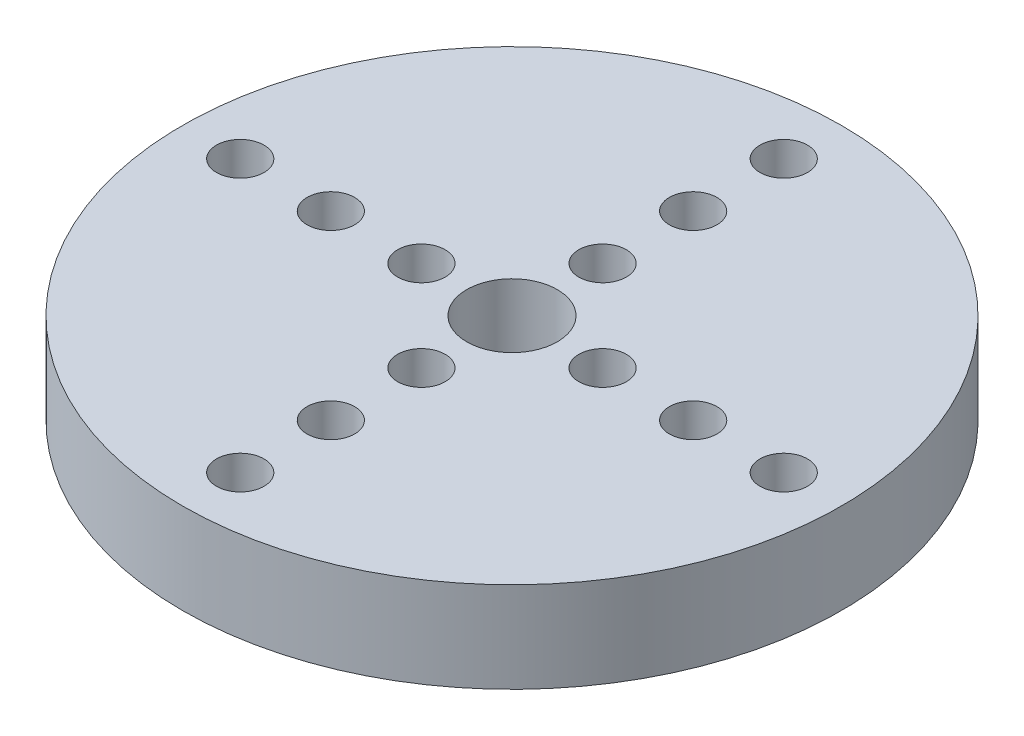
from build123d import *

# Parameters (mm, degrees)
SKETCH_1_R          = 29.105
EXTRUDE_1_DEPTH     = 8
SKETCH_2_R          = 4
CUT_EXTRUDE_1_DEPTH = 8
SKETCH_3_R          = 2.1
CUT_EXTRUDE_2_DEPTH = 8


with BuildPart() as part:
    # 스케치1 → 보스-돌출1 (new body)
    with BuildSketch(Plane(origin=(0, 0, 0), x_dir=(1, 0, 0), z_dir=(0, 1, 0))):
        Circle(SKETCH_1_R)
    extrude(amount=EXTRUDE_1_DEPTH)

    # 스케치2 → 컷-돌출1 (cut)
    with BuildSketch(Plane(origin=(0, 8, 0), x_dir=(1, 0, 0), z_dir=(0, 1, 0))):
        Circle(SKETCH_2_R)
    extrude(amount=-CUT_EXTRUDE_1_DEPTH, mode=Mode.SUBTRACT)

    # 스케치3 → 컷-돌출2 (cut)
    with BuildSketch(Plane(origin=(0, 8, 0), x_dir=(1, 0, 0), z_dir=(0, 1, 0))):
        with Locations((0, 8)):
            Circle(SKETCH_3_R)
        with Locations((0, 16)):
            Circle(SKETCH_3_R)
        with Locations((0, 24)):
            Circle(SKETCH_3_R)
        with Locations((-8, 0)):
            Circle(SKETCH_3_R)
        with Locations((-16, 0)):
            Circle(SKETCH_3_R)
        with Locations((-24, 0)):
            Circle(SKETCH_3_R)
        with Locations((0, -8)):
            Circle(SKETCH_3_R)
        with Locations((0, -16)):
            Circle(SKETCH_3_R)
        with Locations((0, -24)):
            Circle(SKETCH_3_R)
        with Locations((8, 0)):
            Circle(SKETCH_3_R)
        with Locations((16, 0)):
            Circle(SKETCH_3_R)
        with Locations((24, 0)):
            Circle(SKETCH_3_R)
    extrude(amount=-CUT_EXTRUDE_2_DEPTH, mode=Mode.SUBTRACT)


solid = part.part
